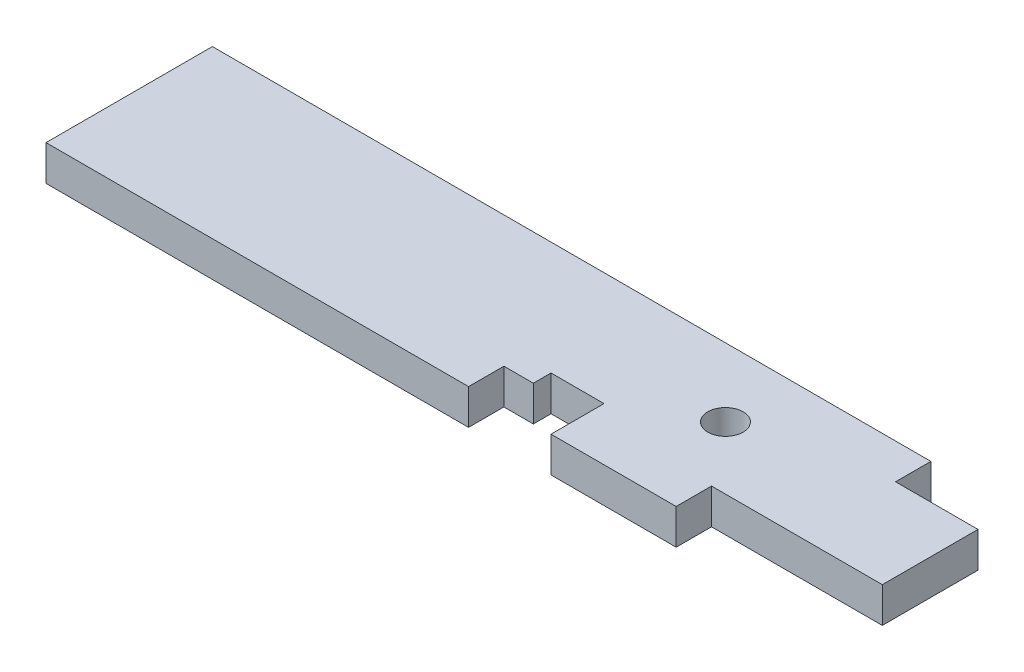
from build123d import *

# Parameters (mm, degrees)
SKETCH1_R           = 19.05
BOSS_EXTRUDE1_DEPTH = 38.1
CUT_EXTRUDE5_DEPTH  = 39.1
SKETCH8_W           = 184.15
SKETCH8_H           = 38.1127
CUT_EXTRUDE6_DEPTH  = 39.1


with BuildPart() as part:
    # Sketch1 → Boss-Extrude1 (new body)
    with BuildSketch(Plane(origin=(0, 0, 0), x_dir=(1, 0, 0), z_dir=(0, 1, 0))):
        Polygon((0, 0), (774.7, 0), (774.7, -38.1), (863.6, -38.1), (863.6, -179.3875), (0, -179.3875), align=None)
        with Locations((627.126, -73.914)):
            Circle(SKETCH1_R, mode=Mode.SUBTRACT)
    extrude(amount=BOSS_EXTRUDE1_DEPTH)

    # Sketch7 → Cut-Extrude5 (cut, through all)
    with BuildSketch(Plane(origin=(0, 38.1, 0), x_dir=(1, 0, 0), z_dir=(0, 1, 0))):
        Polygon((455.6125, -141.2875), (487.3625, -141.2875), (487.3625, -122.2375), (544.5125, -122.2375), (544.5125, -179.3875), (455.6125, -179.3875), align=None)
    extrude(amount=-CUT_EXTRUDE5_DEPTH, mode=Mode.SUBTRACT)

    # Sketch8 → Cut-Extrude6 (cut, through all)
    with BuildSketch(Plane(origin=(0, 38.1, 0), x_dir=(1, 0, 0), z_dir=(0, 1, 0))):
        with Locations((771.525, -160.33115)):
            Rectangle(SKETCH8_W, SKETCH8_H)
    extrude(amount=-CUT_EXTRUDE6_DEPTH, mode=Mode.SUBTRACT)


solid = part.part
